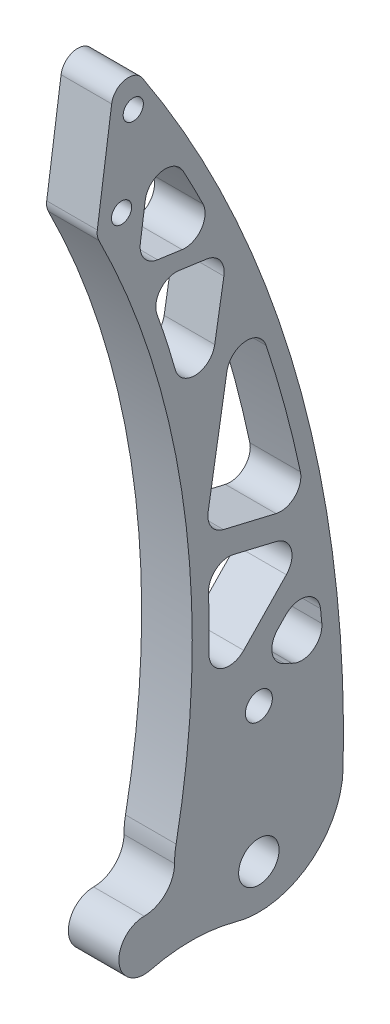
from build123d import *

# Parameters (mm, degrees)
SKETCH1_R           = 6
BOSS_EXTRUDE1_DEPTH = 15
SKETCH2_R           = 4
CUT_EXTRUDE1_DEPTH  = 16
SKETCH3_R           = 3
CUT_EXTRUDE2_DEPTH  = 16
CUT_EXTRUDE3_DEPTH  = 16
FILLET1_R           = 6
SKETCH5_R           = 7.5
BOSS_EXTRUDE2_DEPTH = 15
FILLET2_R           = 5


with BuildPart() as part:
    # Sketch1 → Boss-Extrude1 (new body)
    with BuildSketch(Plane(origin=(0, 0, 0), x_dir=(0, 0, -1), z_dir=(1, 0, 0))):
        with BuildLine():
            ThreePointArc((24.992781164, -0.60074095), (9.243822678, 113.703988064), (-41.858816097, 217.155044504))
            Line((-41.858816097, 217.155044504), (-48.12160564, 172.59298141))
            ThreePointArc((-48.12160564, 172.59298141), (-22.274376436, 90.661190514), (-24.538993202, 4.778892408))
            ThreePointArc((-24.538993202, 4.778892408), (2.400538477, 24.88448141), (25, 0))
            ThreePointArc((25, 0), (24.998195226, -0.30039216), (24.992781164, -0.60074095))
        make_face()
        with BuildLine():
            ThreePointArc((-24.538993202, 4.778892408), (-2.699369305, -24.853840857), (24.992781164, -0.60074095))
            ThreePointArc((24.992781164, -0.60074095), (24.998195226, -0.30039216), (25, 0))
            ThreePointArc((25, 0), (2.400538477, 24.88448141), (-24.538993202, 4.778892408))
        make_face()
        with Locations((0, -12)):
            Circle(SKETCH1_R, mode=Mode.SUBTRACT)
    extrude(amount=BOSS_EXTRUDE1_DEPTH)

    # Sketch2 → Cut-Extrude1 (cut, through all)
    with BuildSketch(Plane(origin=(15, 0, 0), x_dir=(0, 0, -1), z_dir=(1, 0, 0))):
        with Locations((0, 28)):
            Circle(SKETCH2_R)
    extrude(amount=-CUT_EXTRUDE1_DEPTH, mode=Mode.SUBTRACT)

    # Sketch3 → Cut-Extrude2 (cut, through all)
    with BuildSketch(Plane(origin=(15, 0, 0), x_dir=(0, 0, -1), z_dir=(1, 0, 0))):
        with Locations((-40.714528231, 175)):
            Circle(SKETCH3_R)
        with Locations((-37.235200707, 199.756701719)):
            Circle(SKETCH3_R)
    extrude(amount=-CUT_EXTRUDE2_DEPTH, mode=Mode.SUBTRACT)

    # Sketch4 → Cut-Extrude3 (cut, through all)
    with BuildSketch(Plane(origin=(15, 0, 0), x_dir=(0, 0, -1), z_dir=(1, 0, 0))):
        with BuildLine():
            ThreePointArc((-11.749836025, 155.008629259), (-20.960958666, 173.77628952), (-31.260870979, 191.969190837))
            Line((-31.260870979, 191.969190837), (-35.976814508, 158.413509038))
            Line((-35.976814508, 158.413509038), (-11.749836025, 155.008629259))
        make_face()
        with BuildLine():
            Line((-9.354323007, 149.622823998), (-33.760235475, 153.052851308))
            ThreePointArc((-33.760235475, 153.052851308), (-24.416431689, 125.419954523), (-18.166319592, 96.927503721))
            Line((-18.166319592, 96.927503721), (-9.354323007, 149.622823998))
        make_face()
        with BuildLine():
            ThreePointArc((14.161868129, 72.691486719), (5.930300275, 107.334766496), (-5.730334656, 140.979158838))
            Line((-5.730334656, 140.979158838), (-15.958464631, 79.815428272))
            Line((-15.958464631, 79.815428272), (14.161868129, 72.691486719))
        make_face()
        with BuildLine():
            Line((15.468075791, 65.189422352), (-15.356589243, 72.479949778))
            ThreePointArc((-15.356589243, 72.479949778), (-14.750380465, 52.717361117), (-15.619336812, 32.964581198))
            Line((-15.619336812, 32.964581198), (15.468075791, 65.189422352))
        make_face()
        with BuildLine():
            ThreePointArc((19.721068997, 24.377203305), (18.614609922, 40.455333735), (16.779570125, 56.466678425))
            Line((16.779570125, 56.466678425), (-2, 37))
            ThreePointArc((-2, 37), (10.561248293, 33.615157675), (19.721068997, 24.377203305))
        make_face()
    extrude(amount=-CUT_EXTRUDE3_DEPTH, mode=Mode.SUBTRACT)

    # Fillet1
    fillet1_edges = [part.edges().sort_by_distance(p)[0] for p in [
        (7.5, 155.008629259, 11.749836025),
        (7.5, 158.413509038, 35.976814508),
        (7.5, 191.969190837, 31.260870979),
        (7.5, 96.927503721, 18.166319592),
        (7.5, 153.052851308, 33.760235475),
        (7.5, 149.622823998, 9.354323007),
        (7.5, 72.691486719, -14.161868129),
        (7.5, 79.815428272, 15.958464631),
        (7.5, 140.979158838, 5.730334656),
        (7.5, 32.964581198, 15.619336812),
        (7.5, 72.479949778, 15.356589243),
        (7.5, 65.189422352, -15.468075791),
        (7.5, 24.377203305, -19.721068997),
        (7.5, 37, 2),
        (7.5, 56.466678425, -16.779570125),
    ]]
    fillet(fillet1_edges, radius=FILLET1_R)

    # Sketch5 → Boss-Extrude2 (add)
    with BuildSketch(Plane(origin=(15, 0, 0), x_dir=(0, 0, -1), z_dir=(1, 0, 0))):
        with BuildLine():
            ThreePointArc((-34, -9), (-28.696699141, -11.196699141), (-26.5, -16.5))
            ThreePointArc((-26.5, -16.5), (-28.087357429, -21.114180081), (-32.177508753, -23.775199355))
            ThreePointArc((-32.177508753, -23.775199355), (-19.40613231, -22.280390349), (-6.675855702, -24.092176129))
            ThreePointArc((-6.675855702, -24.092176129), (-19.898447082, -15.134457497), (-25, 0))
            ThreePointArc((-25, 0), (-27.636038969, -6.363961031), (-34, -9))
        make_face()
        with Locations((-34, -16.5)):
            Circle(SKETCH5_R)
    extrude(amount=-BOSS_EXTRUDE2_DEPTH)

    # Fillet2
    fillet2_edges = [part.edges().sort_by_distance(p)[0] for p in [
        (7.5, 172.59298141, 48.12160564),
        (7.5, 217.155044504, 41.858816097),
    ]]
    fillet(fillet2_edges, radius=FILLET2_R)


solid = part.part
